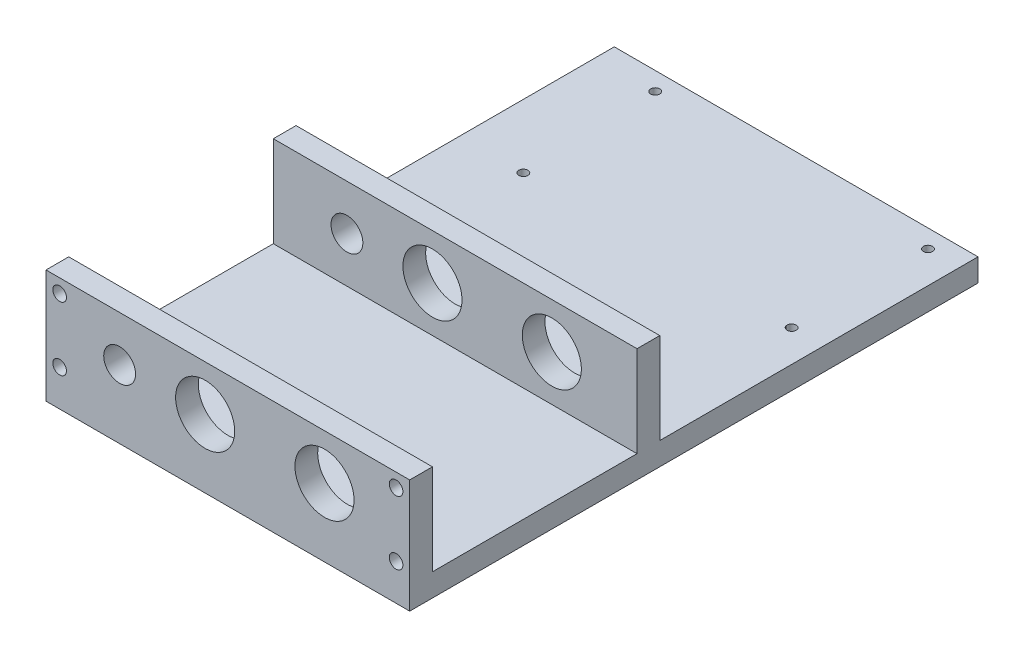
from build123d import *

# Parameters (mm, degrees)
SKETCH_1_W               = 80
SKETCH_1_H               = 25
EXTRUDE_1_DEPTH          = 5
SKETCH_2_W               = 80
SKETCH_2_H               = 5
EXTRUDE_2_DEPTH          = 120
SKETCH_3_W               = 80
SKETCH_3_H               = 5
EXTRUDE_3_DEPTH          = 20
SKETCH_4_R               = 1.5
CUT_EXTRUDE_1_DEPTH      = 20
SKETCH_5_R               = 6.5
CUT_EXTRUDE_2_DEPTH      = 121
CUT_EXTRUDE_2_DEPTH_BACK = 6
SKETCH_6_R               = 3.5
CUT_EXTRUDE_3_DEPTH      = 121
CUT_EXTRUDE_3_DEPTH_BACK = 6
SKETCH_7_R               = 1
CUT_EXTRUDE_4_DEPTH      = 20


with BuildPart() as part:
    # 스케치1 → 보스-돌출1 (new body)
    with BuildSketch(Plane.XY):
        with Locations((40, 12.5)):
            Rectangle(SKETCH_1_W, SKETCH_1_H)
    extrude(amount=EXTRUDE_1_DEPTH)

    # 스케치2 → 보스-돌출2 (add)
    with BuildSketch(Plane(origin=(0, 0, 0), x_dir=(-1, 0, 0), z_dir=(0, 0, -1))):
        with Locations((-40, 2.5)):
            Rectangle(SKETCH_2_W, SKETCH_2_H)
    extrude(amount=EXTRUDE_2_DEPTH)

    # 스케치3 → 보스-돌출3 (add)
    with BuildSketch(Plane(origin=(0, 5, 0), x_dir=(1, 0, 0), z_dir=(0, 1, 0))):
        with Locations((40, 47.5)):
            Rectangle(SKETCH_3_W, SKETCH_3_H)
    extrude(amount=EXTRUDE_3_DEPTH)

    # 스케치4 → 컷-돌출1 (cut)
    with BuildSketch(Plane(origin=(0, 0, 0), x_dir=(-1, 0, 0), z_dir=(0, 0, -1))):
        with Locations((-77, 22)):
            Circle(SKETCH_4_R)
        with Locations((-77, 8)):
            Circle(SKETCH_4_R)
        with Locations((-3, 22)):
            Circle(SKETCH_4_R)
        with Locations((-3, 8)):
            Circle(SKETCH_4_R)
    extrude(amount=-CUT_EXTRUDE_1_DEPTH, mode=Mode.SUBTRACT)

    # 스케치5 → 컷-돌출2 (cut, two sides)
    with BuildSketch(Plane(origin=(0, 0, 0), x_dir=(-1, 0, 0), z_dir=(0, 0, -1))) as cut_extrude_2_sk:
        with Locations((-61.258324532, 15)):
            Circle(SKETCH_5_R)
        with Locations((-35.004725497, 15)):
            Circle(SKETCH_5_R)
    extrude(amount=CUT_EXTRUDE_2_DEPTH, mode=Mode.SUBTRACT)
    extrude(cut_extrude_2_sk.sketch, amount=-CUT_EXTRUDE_2_DEPTH_BACK, mode=Mode.SUBTRACT)

    # 스케치6 → 컷-돌출3 (cut, two sides)
    with BuildSketch(Plane(origin=(0, 0, 0), x_dir=(-1, 0, 0), z_dir=(0, 0, -1))) as cut_extrude_3_sk:
        with Locations((-16.191806112, 15)):
            Circle(SKETCH_6_R)
    extrude(amount=CUT_EXTRUDE_3_DEPTH, mode=Mode.SUBTRACT)
    extrude(cut_extrude_3_sk.sketch, amount=-CUT_EXTRUDE_3_DEPTH_BACK, mode=Mode.SUBTRACT)

    # 스케치7 → 컷-돌출4 (cut)
    with BuildSketch(Plane(origin=(0, 5, 0), x_dir=(1, 0, 0), z_dir=(0, 1, 0))):
        with Locations((73, 116)):
            Circle(SKETCH_7_R)
        with Locations((73, 86)):
            Circle(SKETCH_7_R)
        with Locations((13, 116)):
            Circle(SKETCH_7_R)
        with Locations((14, 86)):
            Circle(SKETCH_7_R)
    extrude(amount=-CUT_EXTRUDE_4_DEPTH, mode=Mode.SUBTRACT)


solid = part.part
